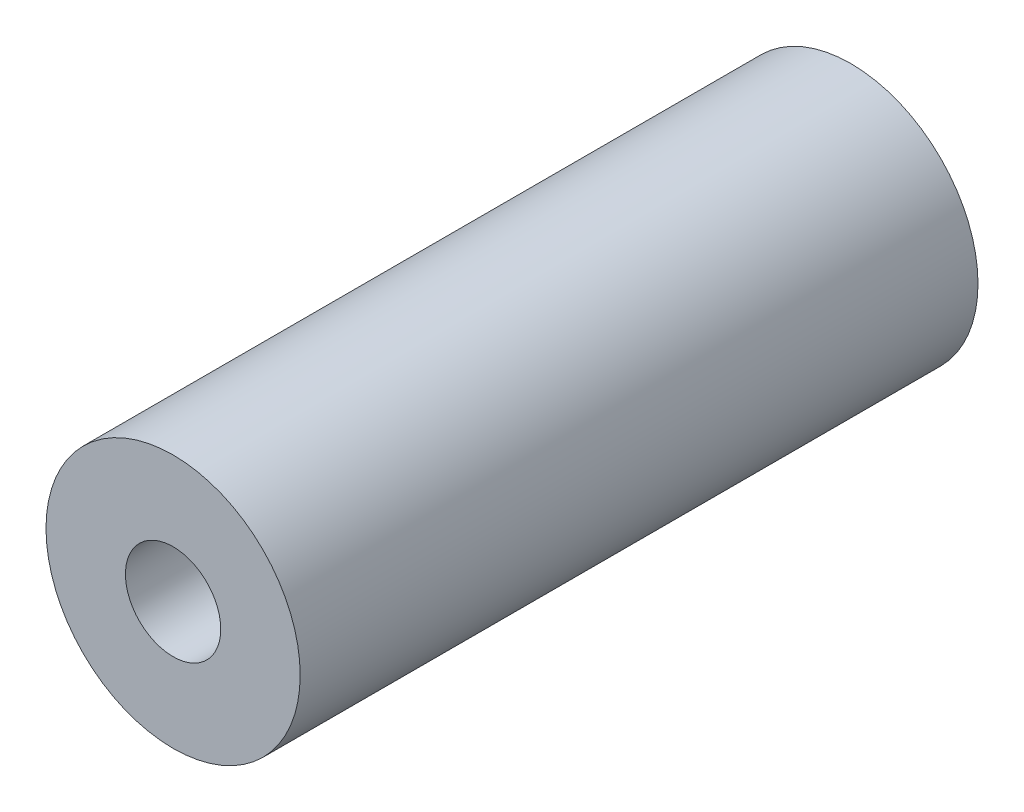
from build123d import *

# Parameters (mm, degrees)
SKETCH2_R           = 4.7625
SKETCH2_R_2         = 1.78562
BOSS_EXTRUDE1_DEPTH = 25.4


with BuildPart() as part:
    # Sketch2 → Boss-Extrude1 (new body)
    with BuildSketch(Plane.XY):
        Circle(SKETCH2_R)
        Circle(SKETCH2_R_2, mode=Mode.SUBTRACT)
    extrude(amount=BOSS_EXTRUDE1_DEPTH)


solid = part.part
